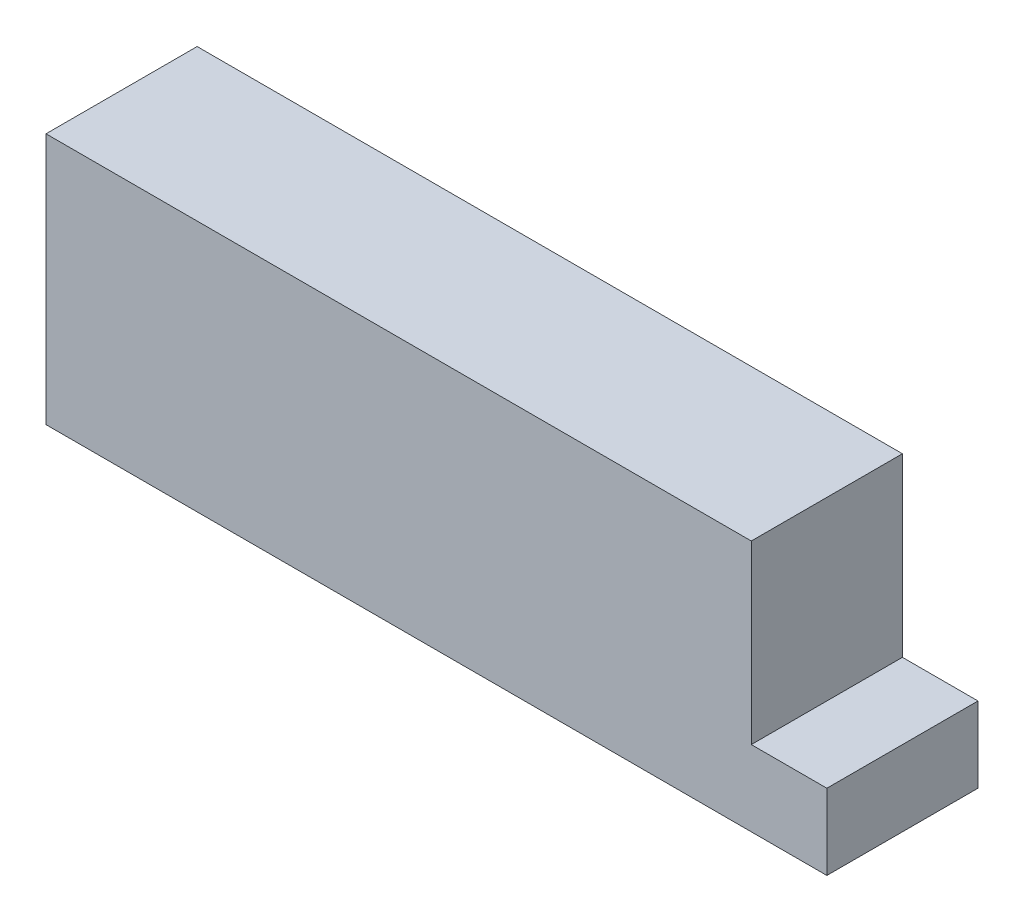
from build123d import *

# Parameters (mm, degrees)
ESQUISSE1_W        = 140
ESQUISSE1_H        = 50
BOSS_EXTRU_1_DEPTH = 30
ESQUISSE3_W        = 30
ESQUISSE3_H        = 15
BOSS_EXTRU_2_DEPTH = 15


with BuildPart() as part:
    # Esquisse1 → Boss.-Extru.1 (new body)
    with BuildSketch(Plane.XY):
        with Locations((6.526190476, 9.523809524)):
            Rectangle(ESQUISSE1_W, ESQUISSE1_H)
    extrude(amount=BOSS_EXTRU_1_DEPTH)

    # Esquisse3 → Boss.-Extru.2 (add)
    with BuildSketch(Plane(origin=(76.526190476, 0, 0), x_dir=(0, 0, -1), z_dir=(1, 0, 0))):
        with Locations((-15, -7.976190476)):
            Rectangle(ESQUISSE3_W, ESQUISSE3_H)
    extrude(amount=BOSS_EXTRU_2_DEPTH)


solid = part.part
